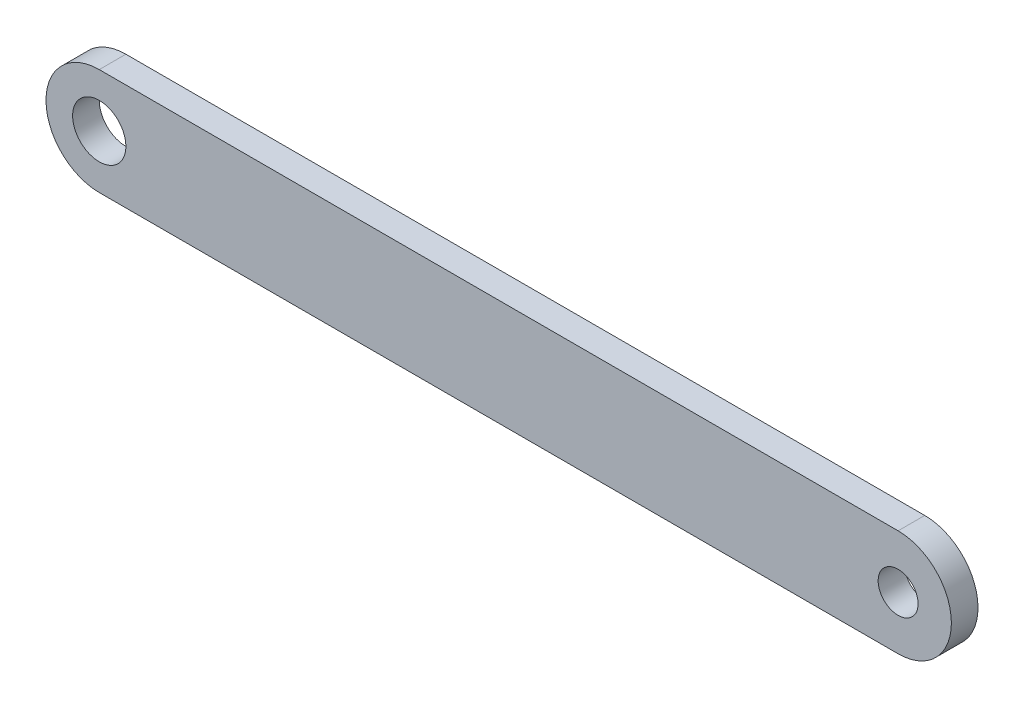
from build123d import *

# Parameters (mm, degrees)
BOSS_EXTRUDE1_DEPTH     = 5
SKETCH2_R               = 10
SKETCH2_R_2             = 7.5
CUT_EXTRUDE1_DEPTH      = 1
CUT_EXTRUDE1_DEPTH_BACK = 11


with BuildPart() as part:
    # Sketch1 → Boss-Extrude1 (new body, symmetric)
    with BuildSketch(Plane.XY):
        with BuildLine():
            Line((-150, 20), (150, 20))
            ThreePointArc((150, 20), (170, 0), (150, -20))
            Line((150, -20), (-150, -20))
            ThreePointArc((-150, -20), (-170, 0), (-150, 20))
        make_face()
    extrude(amount=BOSS_EXTRUDE1_DEPTH, both=True)

    # Sketch2 → Cut-Extrude1 (cut, two sides)
    with BuildSketch(Plane.XY.offset(5)) as cut_extrude1_sk:
        with Locations((-150, 0)):
            Circle(SKETCH2_R)
        with Locations((150, 0)):
            Circle(SKETCH2_R_2)
    extrude(amount=CUT_EXTRUDE1_DEPTH, mode=Mode.SUBTRACT)
    extrude(cut_extrude1_sk.sketch, amount=-CUT_EXTRUDE1_DEPTH_BACK, mode=Mode.SUBTRACT)


solid = part.part
